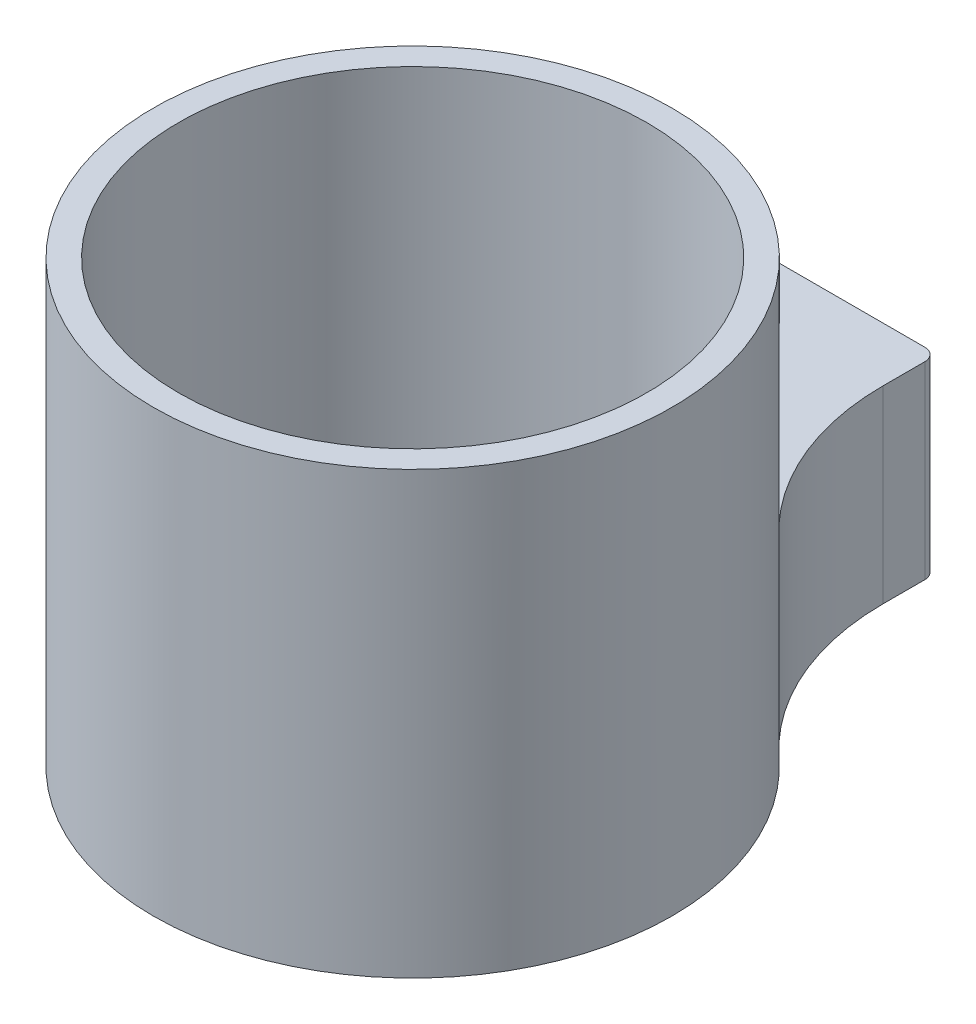
from build123d import *

# Parameters (mm, degrees)
ESQUISSE1_W                    = 15
ESQUISSE1_H                    = 15
BOSS_EXTRU_1_DEPTH             = 15
TROUS_DE_CENTRAGE_5_0MM1_D     = 6.4
TROUS_DE_CENTRAGE_5_0MM1_DEPTH = 10
TROUS_DE_CENTRAGE_5_0MM1_TIP   = 1.922753981
BOSS_EXTRU_2_DEPTH             = 20
BOSS_EXTRU_2_DEPTH_BACK        = 10
ESQUISSE4_R                    = 20.6
ESQUISSE4_R_2                  = 18.6
ESQUISSE5_R                    = 16
BOSS_EXTRU_3_DEPTH             = 5
CONG_1_R                       = 20
CONG_2_R                       = 1
TROUS_DE_CENTRAGE_1_0MM1_D     = 1


with BuildPart() as part:
    # Esquisse1 → Boss.-Extru.1 (new body)
    with BuildSketch(Plane.XY):
        Rectangle(ESQUISSE1_W, ESQUISSE1_H)
    extrude(amount=BOSS_EXTRU_1_DEPTH)

    # Trous de centrage Ø5.0mm1
    with Locations(Plane(origin=(0, 0, 0), x_dir=(-1, 0, 0), z_dir=(0, 0, -1))):
        with Locations((0, 0)):
            Hole(TROUS_DE_CENTRAGE_5_0MM1_D / 2, depth=TROUS_DE_CENTRAGE_5_0MM1_DEPTH)
            with Locations((0, 0, -(TROUS_DE_CENTRAGE_5_0MM1_DEPTH + TROUS_DE_CENTRAGE_5_0MM1_TIP / 2))):  # 118° drill point
                Cone(0, TROUS_DE_CENTRAGE_5_0MM1_D / 2, TROUS_DE_CENTRAGE_5_0MM1_TIP, mode=Mode.SUBTRACT)

    # Esquisse4 → Boss.-Extru.2 (add, two sides: drawn at the far end of the back side and taken through both)
    with BuildSketch(Plane(origin=(0, 7.5, 0), x_dir=(1, 0, 0), z_dir=(0, 1, 0)).offset(-BOSS_EXTRU_2_DEPTH_BACK)):
        with Locations(Location((0, -34.186192952, 0), (0, 0, 270))):
            Circle(ESQUISSE4_R)
        with Locations(Location((0, -34.186192952, 0), (0, 0, 270))):
            Circle(ESQUISSE4_R_2, mode=Mode.SUBTRACT)
    extrude(amount=BOSS_EXTRU_2_DEPTH + BOSS_EXTRU_2_DEPTH_BACK)

    # Esquisse5 → Boss.-Extru.3 (add)
    with BuildSketch(Plane.XZ.offset(2.5)):
        with BuildLine():
            Line((-7.5, 15), (7.5, 15))
            ThreePointArc((7.5, 15), (0, 54.786192952), (-7.5, 15))
        make_face()
        with Locations(Location((0, 34.186192952, 0), (0, 0, 90))):
            Circle(ESQUISSE5_R, mode=Mode.SUBTRACT)
    extrude(amount=BOSS_EXTRU_3_DEPTH)

    # Congé1
    cong_1_edges = [part.edges().sort_by_distance(p)[0] for p in [
        (-7.5, 2.5, 15),
        (7.5, 2.5, 15),
    ]]
    fillet(cong_1_edges, radius=CONG_1_R)

    # Congé2
    cong_2_edges = [part.edges().sort_by_distance(p)[0] for p in [
        (-7.5, 0, 0),
        (7.5, 0, 0),
    ]]
    fillet(cong_2_edges, radius=CONG_2_R)

    # Trous de centrage Ø1.0mm1 (through all)
    with Locations(Plane(origin=(0, 7.5, 0), x_dir=(1, 0, 0), z_dir=(0, 1, 0))):
        with Locations((6, -13.54037013)):
            Hole(TROUS_DE_CENTRAGE_1_0MM1_D / 2)


solid = part.part
